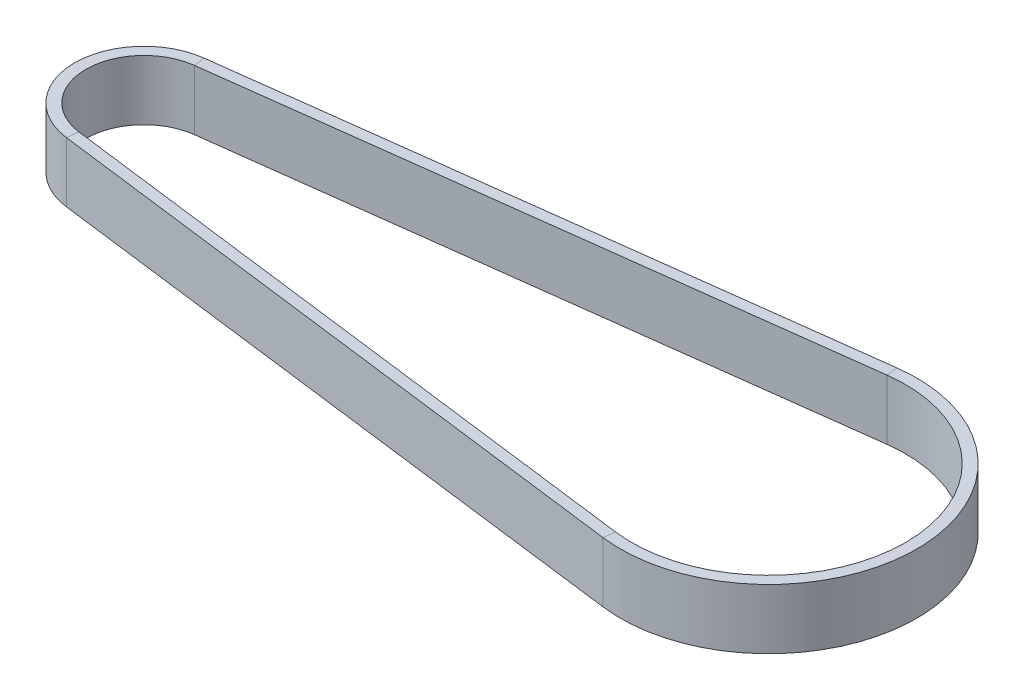
from build123d import *

# Parameters (mm, degrees)
SKETCH2_W = 3
SKETCH2_H = 16


with BuildPart() as part:
    # Sweep1: sweep along a path in Sketch1
    with BuildLine(Plane(origin=(0, 0, 0), x_dir=(1, 0, 0), z_dir=(0, 1, 0))) as sweep1_path:
        Line((911.246503705, -166.426790126), (747.340056999, -145.594382002))
        ThreePointArc((747.340056999, -145.594382002), (732.483502973, -128.730051617), (747.340056999, -111.865721231))
        Line((747.340056999, -111.865721231), (911.246503705, -91.033313108))
        ThreePointArc((911.246503705, -91.033313108), (954.037735883, -128.730051617), (911.246503705, -166.426790126))
    # Sketch2 → Sweep1 (sweep)
    with BuildSketch(Plane(origin=(911.246503705, 0, 91.033313108), x_dir=(-0.1260850573004516, 0, -0.9920194344495182), z_dir=(0.9920194344495182, 0, -0.1260850573004516))):
        Rectangle(SKETCH2_W, SKETCH2_H)
    sweep(path=sweep1_path.line)


solid = part.part
